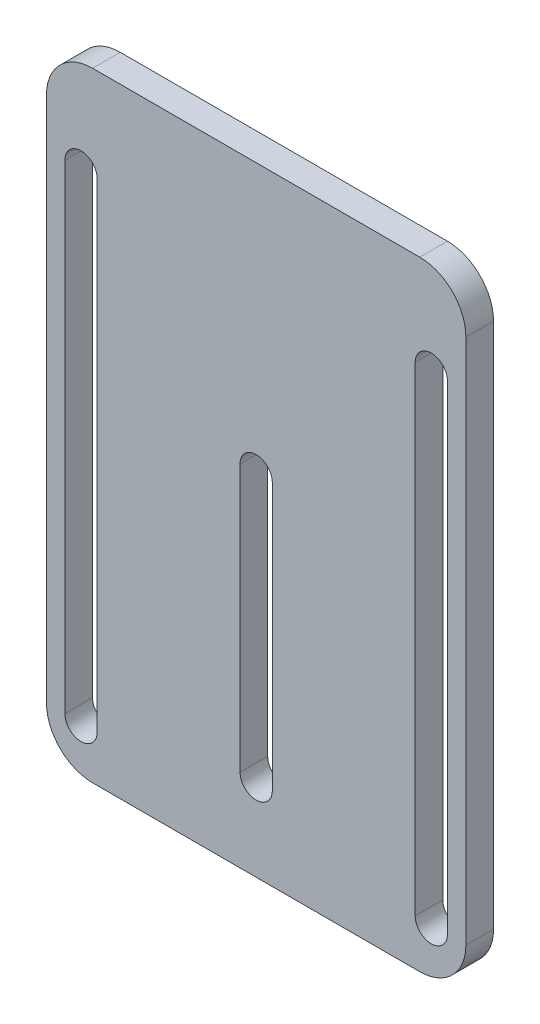
from build123d import *

# Parameters (mm, degrees)
BOSS_EXTRUDE1_DEPTH = 6


with BuildPart() as part:
    # Sketch1 → Boss-Extrude1 (new body)
    with BuildSketch(Plane.XY):
        with BuildLine():
            Line((-35.5, -67.136177844), (35.5, -67.136177844))
            ThreePointArc((35.5, -67.136177844), (42.571067812, -64.207245656), (45.5, -57.136177844))
            Line((45.5, -57.136177844), (45.5, 57.136177844))
            ThreePointArc((45.5, 57.136177844), (42.571067812, 64.207245656), (35.5, 67.136177844))
            Line((35.5, 67.136177844), (-35.5, 67.136177844))
            ThreePointArc((-35.5, 67.136177844), (-42.571067812, 64.207245656), (-45.5, 57.136177844))
            Line((-45.5, 57.136177844), (-45.5, -57.136177844))
            ThreePointArc((-45.5, -57.136177844), (-42.571067812, -64.207245656), (-35.5, -67.136177844))
        make_face()
        with BuildLine():
            Line((-34.5, 46.873645637), (-34.5, -57.136177844))
            ThreePointArc((-34.5, -57.136177844), (-38, -60.636177844), (-41.5, -57.136177844))
            Line((-41.5, -57.136177844), (-41.5, 46.873645637))
            ThreePointArc((-41.5, 46.873645637), (-38, 50.373645637), (-34.5, 46.873645637))
        make_face(mode=Mode.SUBTRACT)
        with BuildLine():
            Line((34.5, -57.136177844), (34.5, 46.873645637))
            ThreePointArc((34.5, 46.873645637), (38, 50.373645637), (41.5, 46.873645637))
            Line((41.5, 46.873645637), (41.5, -57.136177844))
            ThreePointArc((41.5, -57.136177844), (38, -60.636177844), (34.5, -57.136177844))
        make_face(mode=Mode.SUBTRACT)
        with BuildLine():
            Line((3.5, 8.791581559), (3.5, -49.136177844))
            ThreePointArc((3.5, -49.136177844), (0, -52.636177844), (-3.5, -49.136177844))
            Line((-3.5, -49.136177844), (-3.5, 8.791581559))
            ThreePointArc((-3.5, 8.791581559), (0, 12.291581559), (3.5, 8.791581559))
        make_face(mode=Mode.SUBTRACT)
    extrude(amount=BOSS_EXTRUDE1_DEPTH)


solid = part.part
